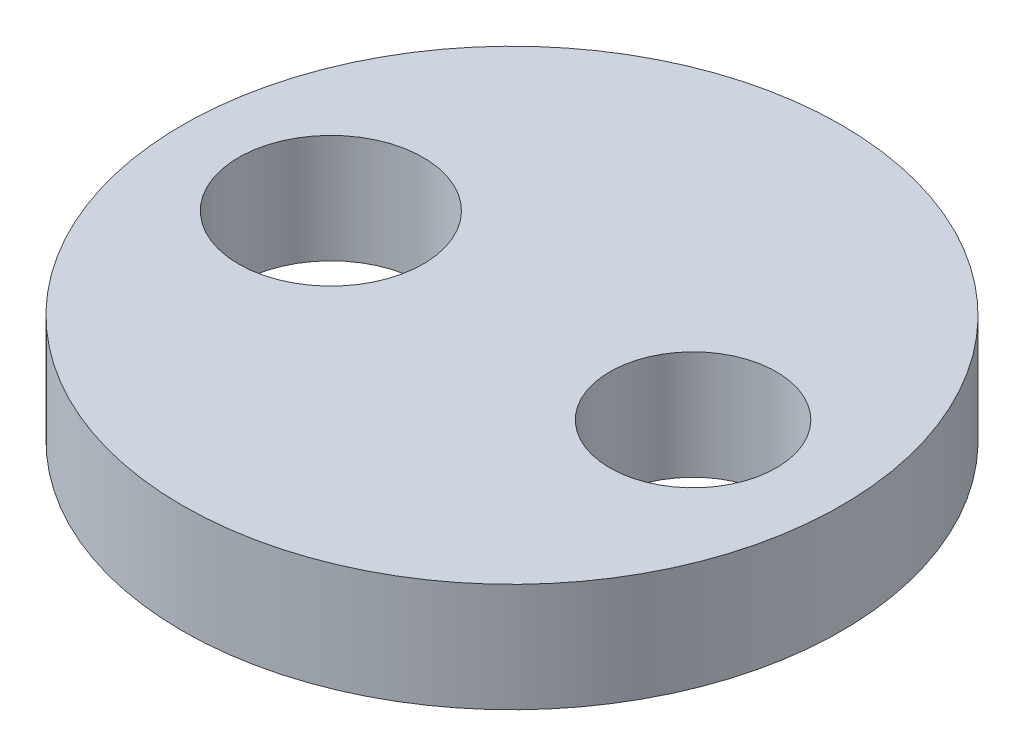
from build123d import *

# Parameters (mm, degrees)
SKETCH1_R           = 9.1
SKETCH1_R_2         = 2.3
SKETCH1_R_3         = 2.55
BOSS_EXTRUDE1_DEPTH = 3


with BuildPart() as part:
    # Sketch1 → Boss-Extrude1 (new body)
    with BuildSketch(Plane(origin=(0, 0, 0), x_dir=(1, 0, 0), z_dir=(0, 1, 0))):
        Circle(SKETCH1_R)
        with Locations((5, 0)):
            Circle(SKETCH1_R_2, mode=Mode.SUBTRACT)
        with Locations((-5, -0.000844513)):
            Circle(SKETCH1_R_3, mode=Mode.SUBTRACT)
    extrude(amount=BOSS_EXTRUDE1_DEPTH)


solid = part.part
